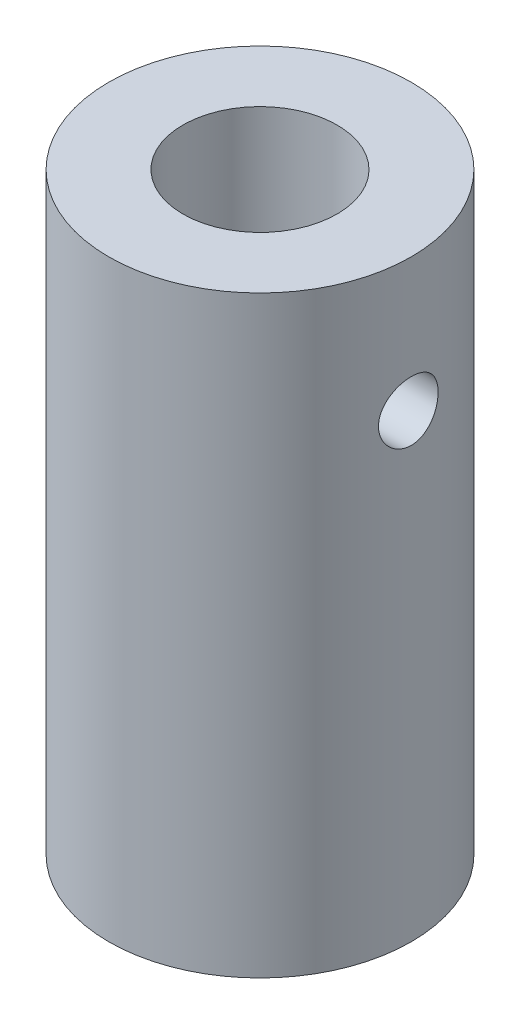
from build123d import *

# Parameters (mm, degrees)
SKETCH1_R           = 12.954
SKETCH1_R_2         = 6.604
BOSS_EXTRUDE1_DEPTH = 50.8
SKETCH3_W           = 2.5527
SKETCH3_H           = 12.954


with BuildPart() as part:
    # Sketch1 → Boss-Extrude1 (new body)
    with BuildSketch(Plane(origin=(0, 0, 0), x_dir=(1, 0, 0), z_dir=(0, 1, 0))):
        Circle(SKETCH1_R)
        Circle(SKETCH1_R_2, mode=Mode.SUBTRACT)
    extrude(amount=BOSS_EXTRUDE1_DEPTH)

    # Sketch3 → 1/4-20 Tapped Hole1 (revolve, cut)
    with BuildSketch(Plane.ZX.offset(39.37)):
        with Locations((1.27635, 6.477)):
            Rectangle(SKETCH3_W, SKETCH3_H)
    revolve(axis=Axis((-6.35, 39.37, 0), (1, 0, 0)), mode=Mode.SUBTRACT)


solid = part.part
